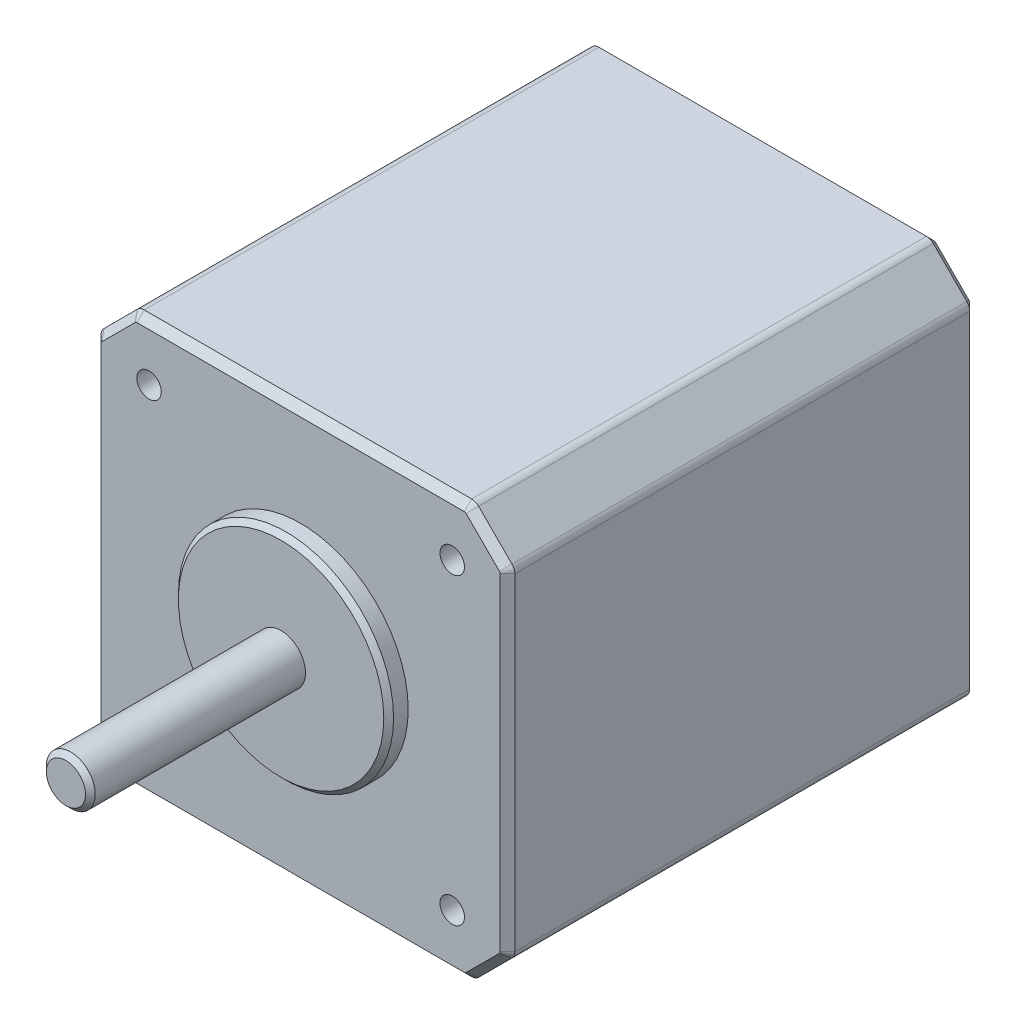
from build123d import *

# Parameters (mm, degrees)
SKETCH1_W                 = 42.3
SKETCH1_H                 = 42.3
BOSS_EXTRUDE1_DEPTH       = 48
M3X0_5_TAPPED_HOLE1_D     = 2.5
M3X0_5_TAPPED_HOLE1_DEPTH = 6
M3X0_5_TAPPED_HOLE1_TIP   = 0.751075774
CHAMFER1_SIZE             = 4
FILLET1_R                 = 1
SKETCH6_R                 = 11
BOSS_EXTRUDE2_DEPTH       = 2
SKETCH7_R                 = 2.5
BOSS_EXTRUDE3_DEPTH       = 22
CHAMFER2_SIZE             = 0.5
CHAMFER3_SIZE             = 0.75
CHAMFER4_SIZE             = 0.5
CHAMFER6_SIZE             = 0.75


with BuildPart() as part:
    # Sketch1 → Boss-Extrude1 (new body)
    with BuildSketch(Plane.XY):
        Rectangle(SKETCH1_W, SKETCH1_H)
    extrude(amount=-BOSS_EXTRUDE1_DEPTH)

    # M3x0.5 Tapped Hole1
    with Locations(Plane.XY):
        with Locations((-15.5, 15.5), (15.5, 15.5), (15.5, -15.5), (-15.5, -15.5)):
            Hole(M3X0_5_TAPPED_HOLE1_D / 2, depth=M3X0_5_TAPPED_HOLE1_DEPTH)
            with Locations((0, 0, -(M3X0_5_TAPPED_HOLE1_DEPTH + M3X0_5_TAPPED_HOLE1_TIP / 2))):  # 118° drill point
                Cone(0, M3X0_5_TAPPED_HOLE1_D / 2, M3X0_5_TAPPED_HOLE1_TIP, mode=Mode.SUBTRACT)

    # Chamfer1
    chamfer1_edges = [part.edges().sort_by_distance(p)[0] for p in [
        (21.15, -21.15, -24),
        (-21.15, -21.15, -24),
        (-21.15, 21.15, -24),
        (21.15, 21.15, -24),
    ]]
    chamfer(chamfer1_edges, length=CHAMFER1_SIZE)

    # Fillet1
    fillet1_edges = [part.edges().sort_by_distance(p)[0] for p in [
        (-21.15, 17.15, -24),
        (-21.15, -17.15, -24),
        (17.15, -21.15, -24),
        (-17.15, -21.15, -24),
        (21.15, 17.15, -24),
        (21.15, -17.15, -24),
        (-17.15, 21.15, -24),
        (17.15, 21.15, -24),
    ]]
    fillet(fillet1_edges, radius=FILLET1_R)

    # Sketch6 → Boss-Extrude2 (add)
    with BuildSketch(Plane.XY):
        Circle(SKETCH6_R)
    extrude(amount=BOSS_EXTRUDE2_DEPTH)

    # Sketch7 → Boss-Extrude3 (add)
    with BuildSketch(Plane.XY.offset(2)):
        Circle(SKETCH7_R)
    extrude(amount=BOSS_EXTRUDE3_DEPTH)

    # Chamfer2
    chamfer2_edges = [part.edges().sort_by_distance(p)[0] for p in [
        (-2.5, 0, 24),
    ]]
    chamfer(chamfer2_edges, length=CHAMFER2_SIZE)

    # Chamfer3
    chamfer3_edges = [part.edges().sort_by_distance(p)[0] for p in [
        (-21.15, 0, 0),
        (-19.15, -19.15, 0),
        (0, -21.15, 0),
        (19.15, -19.15, 0),
        (21.15, 0, 0),
        (19.15, 19.15, 0),
        (0, 21.15, 0),
        (-19.15, 19.15, 0),
        (-21.073879533, 17.11846987, 0),
        (-17.11846987, 21.073879533, 0),
        (17.11846987, 21.073879533, 0),
        (21.073879533, 17.11846987, 0),
        (21.073879533, -17.11846987, 0),
        (17.11846987, -21.073879533, 0),
        (-17.11846987, -21.073879533, 0),
        (-21.073879533, -17.11846987, 0),
    ]]
    chamfer(chamfer3_edges, length=CHAMFER3_SIZE)

    # Chamfer4
    chamfer4_edges = [part.edges().sort_by_distance(p)[0] for p in [
        (-11, 0, 2),
    ]]
    chamfer(chamfer4_edges, length=CHAMFER4_SIZE)

    # Chamfer6
    chamfer6_edges = [part.edges().sort_by_distance(p)[0] for p in [
        (-21.15, 0, -48),
        (-19.15, -19.15, -48),
        (0, -21.15, -48),
        (-19.15, 19.15, -48),
        (0, 21.15, -48),
        (19.15, 19.15, -48),
        (21.15, 0, -48),
        (19.15, -19.15, -48),
        (-21.073879533, 17.11846987, -48),
        (-17.11846987, 21.073879533, -48),
        (17.11846987, 21.073879533, -48),
        (21.073879533, 17.11846987, -48),
        (21.073879533, -17.11846987, -48),
        (17.11846987, -21.073879533, -48),
        (-17.11846987, -21.073879533, -48),
        (-21.073879533, -17.11846987, -48),
    ]]
    chamfer(chamfer6_edges, length=CHAMFER6_SIZE)


solid = part.part
